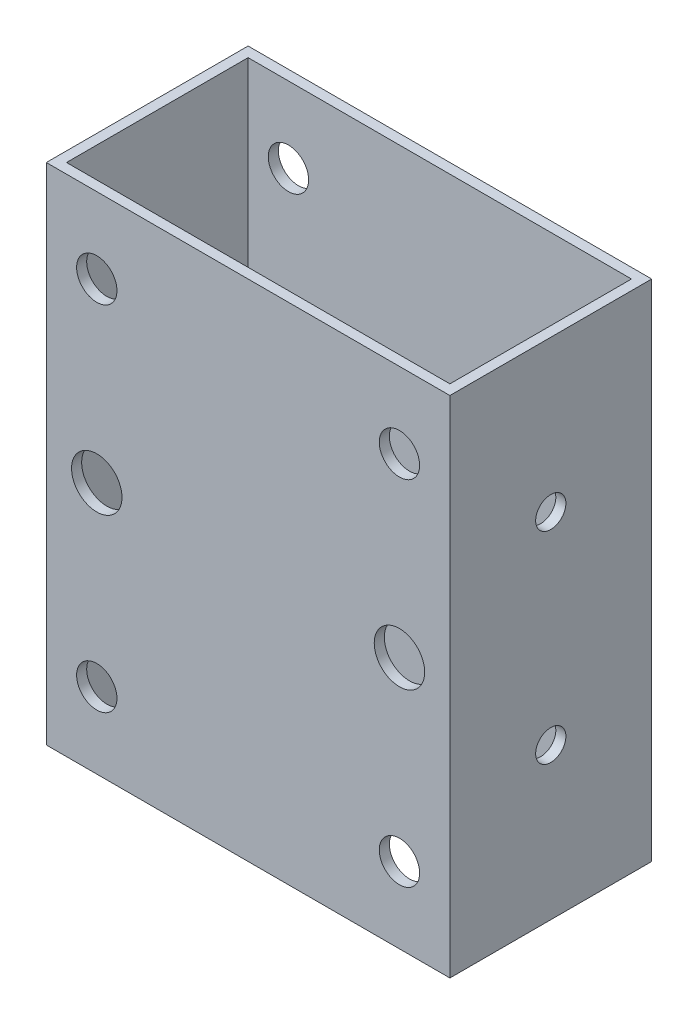
from build123d import *

# Parameters (mm, degrees)
SKETCH1_W           = 80
SKETCH1_H           = 40
SKETCH1_W_2         = 76
SKETCH1_H_2         = 36
BOSS_EXTRUDE1_DEPTH = 100
SKETCH2_R           = 4
SKETCH2_R_2         = 5
CUT_EXTRUDE1_DEPTH  = 40
SKETCH3_R           = 3
CUT_EXTRUDE2_DEPTH  = 80


with BuildPart() as part:
    # Sketch1 → Boss-Extrude1 (new body)
    with BuildSketch(Plane(origin=(0, 0, 0), x_dir=(1, 0, 0), z_dir=(0, 1, 0))):
        with Locations((40, 20)):
            Rectangle(SKETCH1_W, SKETCH1_H)
        with Locations((40, 20)):
            Rectangle(SKETCH1_W_2, SKETCH1_H_2, mode=Mode.SUBTRACT)
    extrude(amount=BOSS_EXTRUDE1_DEPTH)

    # Sketch2 → Cut-Extrude1 (cut)
    with BuildSketch(Plane.XY):
        with Locations((70, 15)):
            Circle(SKETCH2_R)
        with Locations((70, 85)):
            Circle(SKETCH2_R)
        with Locations((10, 15)):
            Circle(SKETCH2_R)
        with Locations((10, 50)):
            Circle(SKETCH2_R_2)
        with Locations((10, 85)):
            Circle(SKETCH2_R)
        with Locations((70, 50)):
            Circle(SKETCH2_R_2)
    extrude(amount=-CUT_EXTRUDE1_DEPTH, mode=Mode.SUBTRACT)

    # Sketch3 → Cut-Extrude2 (cut)
    with BuildSketch(Plane.ZY):
        with Locations((-20, 30)):
            Circle(SKETCH3_R)
        with Locations((-20, 70)):
            Circle(SKETCH3_R)
    extrude(amount=-CUT_EXTRUDE2_DEPTH, mode=Mode.SUBTRACT)


solid = part.part
